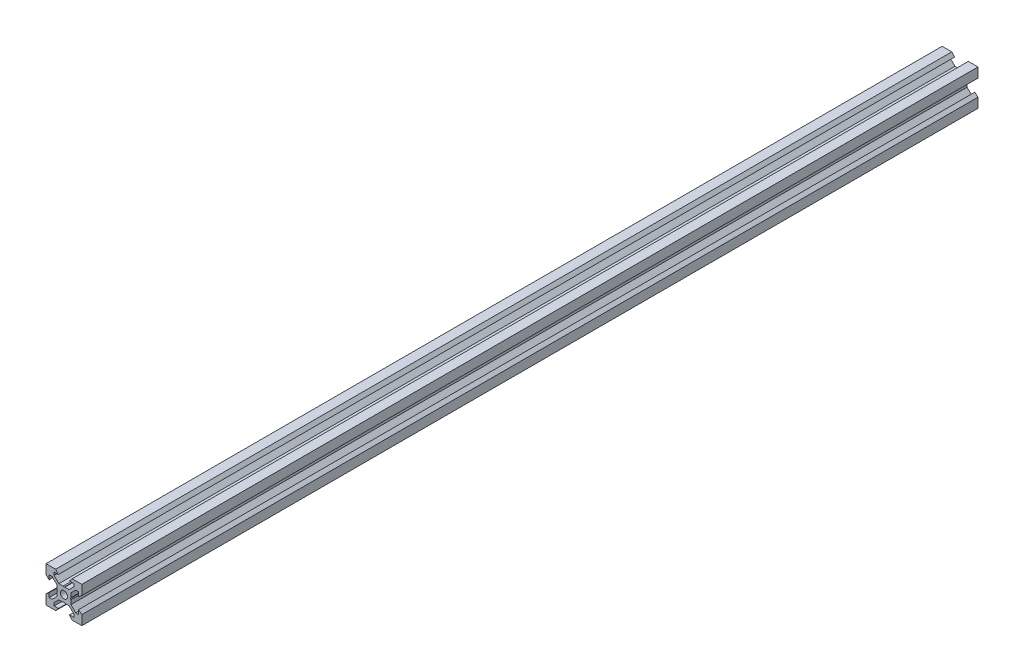
from build123d import *

# Parameters (mm, degrees)
SKETCH1_R           = 2
BOSS_EXTRUDE1_DEPTH = 250


with BuildPart() as part:
    # Sketch1 → Boss-Extrude1 (new body, symmetric)
    with BuildSketch(Plane.XY):
        Polygon((10, 10), (10, 4.610379336), (8.2, 3.1), (8.2, 5.5), (6.560660172, 5.5), (3.9, 2.839339828), (3.9, 0.519615242), (3.6, 0), (3.9, -0.519615242), (3.9, -2.839339828), (6.560660172, -5.5), (8.2, -5.5), (8.2, -3.1), (10, -4.610379336), (10, -10), (4.610379336, -10), (3.1, -8.2), (5.5, -8.2), (5.5, -6.560660172), (2.839339828, -3.9), (0.519615242, -3.9), (0, -3.6), (-0.519615242, -3.9), (-2.839339828, -3.9), (-5.5, -6.560660172), (-5.5, -8.2), (-3.1, -8.2), (-4.610379336, -10), (-10, -10), (-10, -4.610379336), (-8.2, -3.1), (-8.2, -5.5), (-6.560660172, -5.5), (-3.9, -2.839339828), (-3.9, -0.519615242), (-3.6, 0), (-3.9, 0.519615242), (-3.9, 2.839339828), (-6.560660172, 5.5), (-8.2, 5.5), (-8.2, 3.1), (-10, 4.610379336), (-10, 10), (-4.610379336, 10), (-3.1, 8.2), (-5.5, 8.2), (-5.5, 6.560660172), (-2.839339828, 3.9), (-0.519615242, 3.9), (0, 3.6), (0.519615242, 3.9), (2.839339828, 3.9), (5.5, 6.560660172), (5.5, 8.2), (3.1, 8.2), (4.610379336, 10), align=None)
        Circle(SKETCH1_R, mode=Mode.SUBTRACT)
    extrude(amount=BOSS_EXTRUDE1_DEPTH, both=True)


solid = part.part
